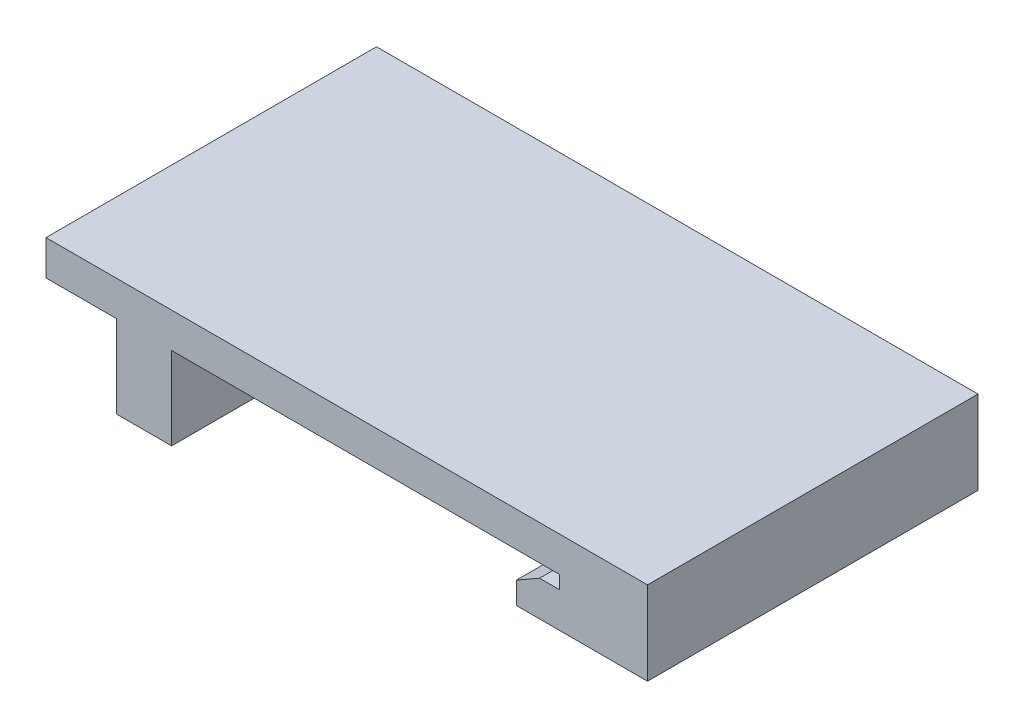
from build123d import *

# Parameters (mm, degrees)
BOSS_EXTRUDE1_DEPTH = 30
SKETCH2_R           = 1.275
CUT_EXTRUDE1_DEPTH  = 5


with BuildPart() as part:
    # Sketch1 → Boss-Extrude1 (new body)
    with BuildSketch(Plane.XY):
        Polygon((0, 0), (19.3, 0), (19.3, -1.2), (17.5, -1.2), (15.4, -2.4), (15.4, -4.4), (27.3, -4.4), (27.3, 3.175), (-27.3, 3.175), (-27.3, 0), (-20.9, 0), (-20.9, -7.5), (-15.9, -7.5), (-15.9, 0), align=None)
    extrude(amount=BOSS_EXTRUDE1_DEPTH)

    # Sketch2 → Cut-Extrude1 (cut)
    with BuildSketch(Plane.ZY.offset(20.9)):
        with Locations((7.5, -3.75)):
            Circle(SKETCH2_R)
        with Locations((22.5, -3.75)):
            Circle(SKETCH2_R)
    extrude(amount=-CUT_EXTRUDE1_DEPTH, mode=Mode.SUBTRACT)


solid = part.part
